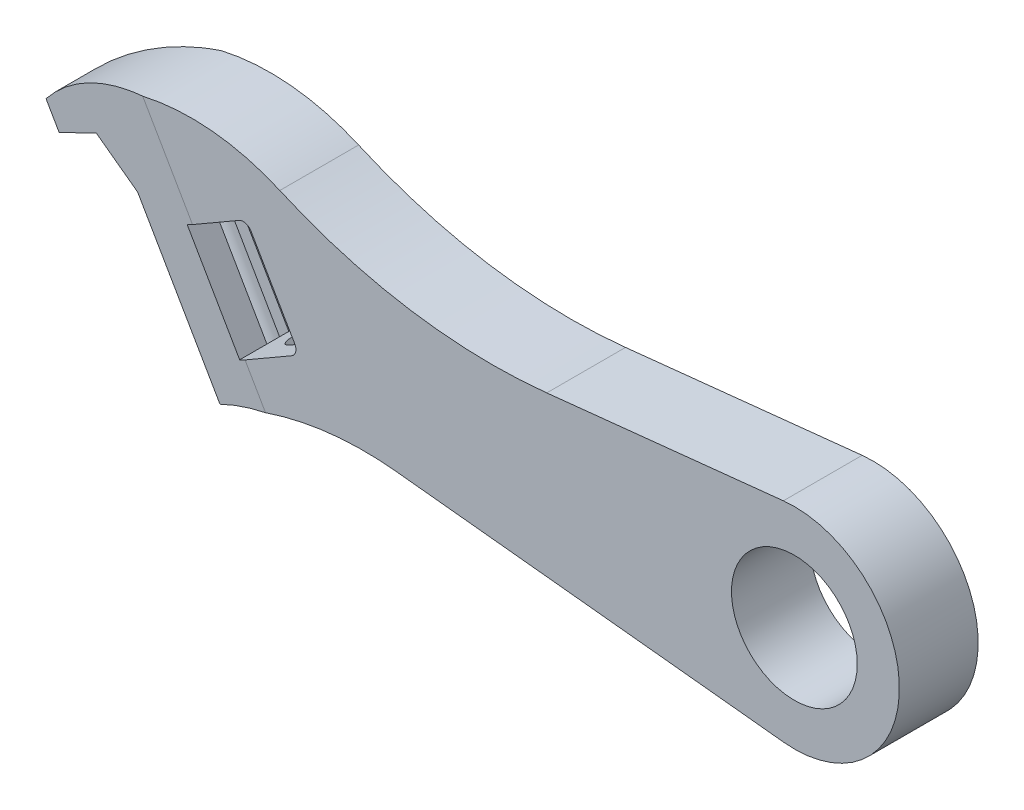
from build123d import *

# Parameters (mm, degrees)
SKETCH1_R               = 7.18463753
BOSS_EXTRUDE1_DEPTH     = 4.5
CUT_EXTRUDE2_START      = 4
SKETCH4_R               = 2
CUT_EXTRUDE2_DEPTH      = 29
CUT_EXTRUDE3_DEPTH      = 29
CUT_EXTRUDE4_DEPTH      = 29
CUT_EXTRUDE4_DEPTH_BACK = 29


with BuildPart() as part:
    # Sketch1 → Boss-Extrude1 (new, symmetric)
    with BuildSketch(Plane.XY):
        with BuildLine():
            Line((-1.254341559, 11.934262744), (-28.289662127, 9.092736051))
            ThreePointArc((-28.289662127, 9.092736051), (-43.850490966, 9.48747573), (-58.786122703, 13.871779345))
            ThreePointArc((-58.786122703, 13.871779345), (-74.520010862, 15.355444557), (-88, 7.106420865))
            Line((-88, 7.106420865), (-86.5, 4.508344654))
            Line((-86.5, 4.508344654), (-81.303847577, 7.508344654))
            Line((-81.303847577, 7.508344654), (-76.107695155, 4.508344654))
            Line((-76.107695155, 4.508344654), (-66.705771366, -11.776265037))
            ThreePointArc((-66.705771366, -11.776265037), (-56.482680545, -7.851988144), (-45.547275152, -7.278887832))
            Line((-45.547275152, -7.278887832), (-1.254341559, -11.934262744))
            ThreePointArc((-1.254341559, -11.934262744), (12, 0), (-1.254341559, 11.934262744))
        make_face()
        Circle(SKETCH1_R, mode=Mode.SUBTRACT)
        with BuildLine():
            Line((-69.509618943, 5.080141424), (-63.509618943, -5.312163422))
            Line((-63.509618943, -5.312163422), (-57.447441117, -1.812163422))
            ThreePointArc((-57.447441117, -1.812163422), (-56.98151529, -1.204957063), (-57.081415713, -0.446138018))
            Line((-57.081415713, -0.446138018), (-62.081415713, 8.21411602))
            ThreePointArc((-62.081415713, 8.21411602), (-62.688622072, 8.680041846), (-63.447441117, 8.580141424))
            Line((-63.447441117, 8.580141424), (-69.509618943, 5.080141424))
        make_face(mode=Mode.SUBTRACT)
    extrude(amount=BOSS_EXTRUDE1_DEPTH, both=True)

    # Sketch4 → Cut-Extrude2 (cut)
    with BuildSketch(Plane(origin=(-23.5771705, 40.836857204, 0), x_dir=(0.8660254037844386, 0.5000000000000003, 0), z_dir=(0.5000000000000003, -0.8660254037844386, 0)).offset(CUT_EXTRUDE2_START)):
        with Locations((-53.6570251, 0)):
            Circle(SKETCH4_R)
    extrude(amount=CUT_EXTRUDE2_DEPTH, mode=Mode.SUBTRACT)

    # Sketch4_4 → Cut-Extrude3 (cut)
    with BuildSketch(Plane(origin=(-23.5771705, 40.836857204, 0), x_dir=(0.8660254037844386, 0.5000000000000003, 0), z_dir=(0.5000000000000003, -0.8660254037844386, 0))):
        with BuildLine():
            Line((-59.095775601, -1.25), (-57.6570251, -1.25))
            Line((-57.6570251, -1.25), (-57.6570251, 1.25))
            Line((-57.6570251, 1.25), (-59.095775601, 1.25))
            ThreePointArc((-59.095775601, 1.25), (-60.6570251, 2), (-62.2182746, 1.25))
            Line((-62.2182746, 1.25), (-66.6570251, 1.25))
            Line((-66.6570251, 1.25), (-66.6570251, -1.25))
            Line((-66.6570251, -1.25), (-62.2182746, -1.25))
            ThreePointArc((-62.2182746, -1.25), (-60.6570251, -2), (-59.095775601, -1.25))
        make_face()
    extrude(amount=CUT_EXTRUDE3_DEPTH, mode=Mode.SUBTRACT)

    # Sketch4_6 → Cut-Extrude4 (cut, two sides: drawn at the far end of the back side and taken through both)
    with BuildSketch(Plane(origin=(-23.5771705, 40.836857204, 0), x_dir=(0.8660254037844386, 0.5000000000000003, 0), z_dir=(0.5000000000000003, -0.8660254037844386, 0)).offset(-CUT_EXTRUDE4_DEPTH_BACK)):
        Polygon((-56.790792146, 4.5), (-72.6570251, 4.5), (-72.6570251, 2), align=None)
        Polygon((-56.790792146, -4.5), (-72.6570251, -2), (-72.6570251, -4.5), align=None)
    extrude(amount=CUT_EXTRUDE4_DEPTH + CUT_EXTRUDE4_DEPTH_BACK, mode=Mode.SUBTRACT)


solid = part.part
